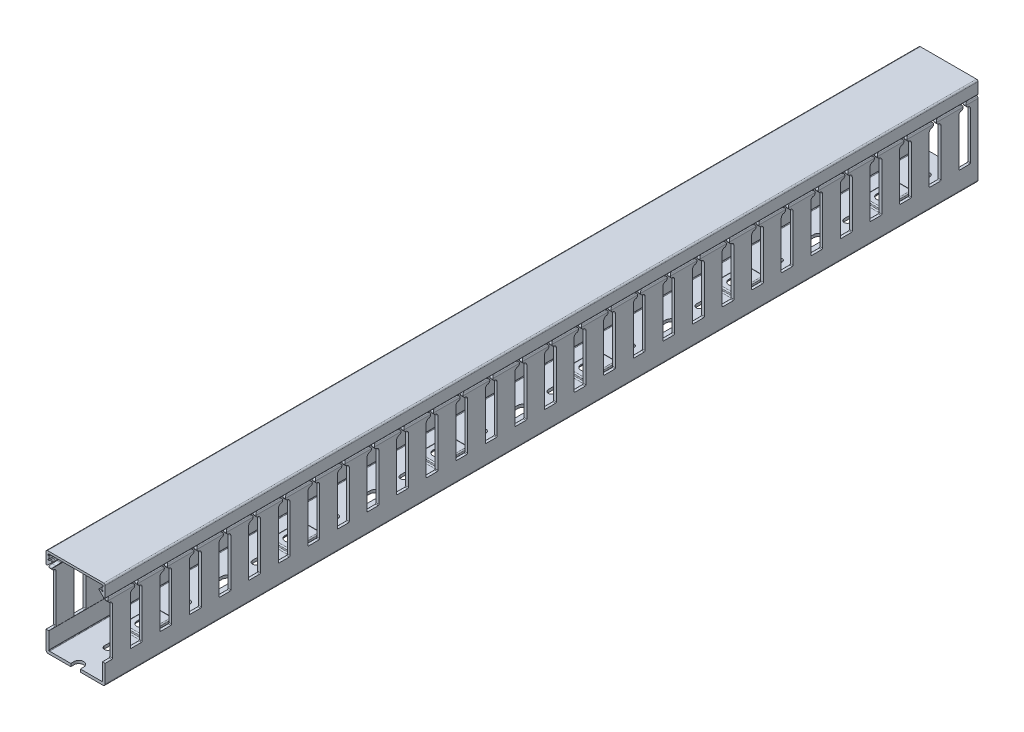
from build123d import *

# Parameters (mm, degrees)
BOSS_EXTRUDE1_START    = -295
BOSS_EXTRUDE1_DEPTH    = 590
BOSS_EXTRUDE2_START    = -295
BOSS_EXTRUDE2_DEPTH    = 590
BOSS_EXTRUDE3_START    = -30.05
SKETCH5_W              = 14
SKETCH5_H              = 21.4142
BOSS_EXTRUDE3_DEPTH    = 4.4
CUT_EXTRUDE1_START     = -30.05
SKETCH6_W              = 12.536
SKETCH6_H              = 19.9502
CUT_EXTRUDE1_DEPTH     = 3.6678
FILLET1_R              = 0.732
LPATTERN1_COUNT        = 6
LPATTERN1_PITCH        = 100
FILLET1_OF_LPATTERN1_R = 0.732
CUT_EXTRUDE2_START     = -31.0500001
CUT_EXTRUDE2_DEPTH     = 62.1000001
LPATTERN2_COUNT        = 7
LPATTERN2_PITCH        = 100
CUT_EXTRUDE3_DEPTH     = 21
LPATTERN4_COUNT        = 32
LPATTERN4_PITCH        = 20


with BuildPart() as part:
    # Sketch3 → Boss-Extrude1 (new body)
    with BuildSketch(Plane.XY.offset(BOSS_EXTRUDE1_START)):
        with BuildLine():
            Line((15.952670815, 24.4903301), (19.152670815, 21.40012602))
            ThreePointArc((19.152670815, 21.40012602), (19.695365564, 21.299543494), (20, 21.759795921))
            Line((20, 21.759795921), (20, 29.05))
            ThreePointArc((20, 29.05), (19.707106781, 29.757106781), (19, 30.05))
            Line((19, 30.05), (-19, 30.05))
            ThreePointArc((-19, 30.05), (-19.707106781, 29.757106781), (-20, 29.05))
            Line((-20, 29.05), (-20, 21.759795921))
            ThreePointArc((-20, 21.759795921), (-19.695365564, 21.299543494), (-19.152670815, 21.40012602))
            Line((-19.152670815, 21.40012602), (-15.952670815, 24.4903301))
            ThreePointArc((-15.952670815, 24.4903301), (-15.836408073, 25.037303297), (-16.3, 25.35))
            Line((-16.3, 25.35), (-17.01977827, 25.35))
            ThreePointArc((-17.01977827, 25.35), (-17.207081567, 25.313591927), (-17.367107455, 25.2096699))
            Line((-17.367107455, 25.2096699), (-17.822136652, 24.770253313))
            ThreePointArc((-17.822136652, 24.770253313), (-18.256292451, 24.689787291), (-18.5, 25.057989233))
            Line((-18.5, 25.057989233), (-18.5, 25.25))
            ThreePointArc((-18.5, 25.25), (-18.470710678, 25.320710678), (-18.4, 25.35))
            Line((-18.4, 25.35), (-18.2, 25.35))
            ThreePointArc((-18.2, 25.35), (-18.058578644, 25.408578644), (-18, 25.55))
            Line((-18, 25.55), (-18, 27.25))
            ThreePointArc((-18, 27.25), (-18.058578644, 27.391421356), (-18.2, 27.45))
            Line((-18.2, 27.45), (-18.4, 27.45))
            ThreePointArc((-18.4, 27.45), (-18.470710678, 27.479289322), (-18.5, 27.55))
            Line((-18.5, 27.55), (-18.5, 28.35))
            ThreePointArc((-18.5, 28.35), (-18.441421356, 28.491421356), (-18.3, 28.55))
            Line((-18.3, 28.55), (18.3, 28.55))
            ThreePointArc((18.3, 28.55), (18.441421356, 28.491421356), (18.5, 28.35))
            Line((18.5, 28.35), (18.5, 27.55))
            ThreePointArc((18.5, 27.55), (18.470710678, 27.479289322), (18.4, 27.45))
            Line((18.4, 27.45), (18.2, 27.45))
            ThreePointArc((18.2, 27.45), (18.058578644, 27.391421356), (18, 27.25))
            Line((18, 27.25), (18, 25.55))
            ThreePointArc((18, 25.55), (18.058578644, 25.408578644), (18.2, 25.35))
            Line((18.2, 25.35), (18.4, 25.35))
            ThreePointArc((18.4, 25.35), (18.470710678, 25.320710678), (18.5, 25.25))
            Line((18.5, 25.25), (18.5, 25.057989233))
            ThreePointArc((18.5, 25.057989233), (18.256292451, 24.689787291), (17.822136652, 24.770253313))
            Line((17.822136652, 24.770253313), (17.367107455, 25.2096699))
            ThreePointArc((17.367107455, 25.2096699), (17.207081567, 25.313591927), (17.01977827, 25.35))
            Line((17.01977827, 25.35), (16.3, 25.35))
            ThreePointArc((16.3, 25.35), (15.836408073, 25.037303297), (15.952670815, 24.4903301))
        make_face()
    extrude(amount=BOSS_EXTRUDE1_DEPTH)


with BuildPart() as body_2:
    # Sketch4 → Boss-Extrude2 (new body)
    with BuildSketch(Plane.XY.offset(BOSS_EXTRUDE2_START)):
        with BuildLine():
            Line((18.2, -27.85), (17.97299254, -27.982981329))
            ThreePointArc((17.97299254, -27.982981329), (17.80433959, -28.106339054), (17.6, -28.15))
            Line((17.6, -28.15), (-17.6, -28.15))
            ThreePointArc((-17.6, -28.15), (-17.80433959, -28.106339054), (-17.97299254, -27.982981329))
            Line((-17.97299254, -27.982981329), (-18.2, -27.85))
            Line((-18.2, -27.85), (-18.08202108, -27.782874671))
            ThreePointArc((-18.08202108, -27.782874671), (-18.095484884, -27.717042747), (-18.1, -27.65))
            Line((-18.1, -27.65), (-18.1, -16.507735027))
            Line((-18.1, -16.507735027), (-18.2, -16.45))
            Line((-18.2, -16.45), (-18.1, -16.392264973))
            Line((-18.1, -16.392264973), (-18.1, 18.84159723))
            ThreePointArc((-18.1, 18.84159723), (-18.066790213, 19.020781205), (-17.971572413, 19.176162533))
            Line((-17.971572413, 19.176162533), (-14.86028457, 22.631597749))
            ThreePointArc((-14.86028457, 22.631597749), (-14.267656312, 22.954958117), (-13.762339314, 23.402646525))
            ThreePointArc((-13.762339314, 23.402646525), (-13.419555232, 23.962019308), (-13.3, 24.607081617))
            Line((-13.3, 24.607081617), (-13.3, 25.85))
            ThreePointArc((-13.3, 25.85), (-13.827207794, 27.122792206), (-15.1, 27.65))
            Line((-15.1, 27.65), (-16.088349161, 27.65))
            ThreePointArc((-16.088349161, 27.65), (-16.887746934, 27.462750198), (-17.520825735, 26.939959112))
            ThreePointArc((-17.520825735, 26.939959112), (-17.828732042, 26.814376215), (-18.12760996, 26.668604651))
            ThreePointArc((-18.12760996, 26.668604651), (-18.451503706, 25.793986483), (-17.618826668, 25.373851922))
            Line((-17.618826668, 25.373851922), (-16.381173332, 25.705480134))
            ThreePointArc((-16.381173332, 25.705480134), (-15.603151885, 25.395081051), (-15.679798622, 24.560940631))
            Line((-15.679798622, 24.560940631), (-19.614717238, 20.190770771))
            ThreePointArc((-19.614717238, 20.190770771), (-19.90037064, 19.724626786), (-20, 19.187074862))
            Line((-20, 19.187074862), (-20, -28.55))
            ThreePointArc((-20, -28.55), (-19.560660172, -29.610660172), (-18.5, -30.05))
            Line((-18.5, -30.05), (18.5, -30.05))
            ThreePointArc((18.5, -30.05), (19.560660172, -29.610660172), (20, -28.55))
            Line((20, -28.55), (20, 19.187074862))
            ThreePointArc((20, 19.187074862), (19.90037064, 19.724626786), (19.614717238, 20.190770771))
            Line((19.614717238, 20.190770771), (15.679798622, 24.560940631))
            ThreePointArc((15.679798622, 24.560940631), (15.603151885, 25.395081051), (16.381173332, 25.705480134))
            Line((16.381173332, 25.705480134), (17.618826668, 25.373851922))
            ThreePointArc((17.618826668, 25.373851922), (18.451503706, 25.793986483), (18.12760996, 26.668604651))
            ThreePointArc((18.12760996, 26.668604651), (17.828732042, 26.814376215), (17.520825735, 26.939959112))
            ThreePointArc((17.520825735, 26.939959112), (16.887746934, 27.462750198), (16.088349161, 27.65))
            Line((16.088349161, 27.65), (15.1, 27.65))
            ThreePointArc((15.1, 27.65), (13.827207794, 27.122792206), (13.3, 25.85))
            Line((13.3, 25.85), (13.3, 24.607081617))
            ThreePointArc((13.3, 24.607081617), (13.419555232, 23.962019308), (13.762339314, 23.402646525))
            ThreePointArc((13.762339314, 23.402646525), (14.267656312, 22.954958117), (14.86028457, 22.631597749))
            Line((14.86028457, 22.631597749), (17.971572413, 19.176162533))
            ThreePointArc((17.971572413, 19.176162533), (18.066790213, 19.020781205), (18.1, 18.84159723))
            Line((18.1, 18.84159723), (18.1, -16.392264973))
            Line((18.1, -16.392264973), (18.2, -16.45))
            Line((18.2, -16.45), (18.1, -16.507735027))
            Line((18.1, -16.507735027), (18.1, -27.65))
            ThreePointArc((18.1, -27.65), (18.095484884, -27.717042747), (18.08202108, -27.782874671))
            Line((18.08202108, -27.782874671), (18.2, -27.85))
        make_face()
    extrude(amount=BOSS_EXTRUDE2_DEPTH)

    # Sketch5 → Boss-Extrude3 (add)
    with BuildSketch(Plane(origin=(0, 0, 0), x_dir=(1, 0, 0), z_dir=(0, 1, 0)).offset(BOSS_EXTRUDE3_START)):
        with Locations((0, -246.5)):
            Rectangle(SKETCH5_W, SKETCH5_H)
    boss_extrude3 = extrude(amount=BOSS_EXTRUDE3_DEPTH)

    # Sketch6 → Cut-Extrude1 (cut)
    with BuildSketch(Plane(origin=(0, 0, 0), x_dir=(1, 0, 0), z_dir=(0, 1, 0)).offset(CUT_EXTRUDE1_START)):
        with Locations((0, -246.5)):
            Rectangle(SKETCH6_W, SKETCH6_H)
    cut_extrude1 = extrude(amount=CUT_EXTRUDE1_DEPTH, mode=Mode.SUBTRACT)

    # Fillet1
    fillet1_edges = [body_2.edges().sort_by_distance(p)[0] for p in [
        (7, -26.9, 257.2071),
        (7, -28.15, 246.5),
        (7, -26.9, 235.7929),
        (0, -28.15, 235.7929),
        (-7, -26.9, 235.7929),
        (-7, -28.15, 246.5),
        (-7, -26.9, 257.2071),
        (0, -28.15, 257.2071),
        (7, -25.65, 246.5),
        (0, -25.65, 235.7929),
        (-7, -25.65, 246.5),
        (0, -25.65, 257.2071),
        (0, -30.05, 256.4751),
        (-6.268, -28.2161, 256.4751),
        (6.268, -30.05, 246.5),
        (6.268, -28.2161, 256.4751),
        (0, -30.05, 236.5249),
        (6.268, -28.2161, 236.5249),
        (-6.268, -30.05, 246.5),
        (-6.268, -28.2161, 236.5249),
        (0, -26.3822, 256.4751),
        (6.268, -26.3822, 246.5),
        (0, -26.3822, 236.5249),
        (-6.268, -26.3822, 246.5),
    ]]
    fillet(fillet1_edges, radius=FILLET1_R)

    # LPattern1: Boss-Extrude3, Cut-Extrude1 ×6
    with Locations(*[(0, 0, -i * LPATTERN1_PITCH) for i in range(1, LPATTERN1_COUNT)]):
        add(boss_extrude3)
        add(cut_extrude1, mode=Mode.SUBTRACT)

    # Fillet1 of LPattern1
    fillet1_of_lpattern1_edges = [body_2.edges().sort_by_distance(p)[0] for p in [
        (7, -26.9, 157.2071),
        (7, -28.15, 146.5),
        (7, -26.9, 135.7929),
        (0, -28.15, 135.7929),
        (-7, -26.9, 135.7929),
        (-7, -28.15, 146.5),
        (-7, -26.9, 157.2071),
        (0, -28.15, 157.2071),
        (7, -25.65, 146.5),
        (0, -25.65, 135.7929),
        (-7, -25.65, 146.5),
        (0, -25.65, 157.2071),
        (0, -30.05, 156.4751),
        (-6.268, -28.2161, 156.4751),
        (6.268, -30.05, 146.5),
        (6.268, -28.2161, 156.4751),
        (0, -30.05, 136.5249),
        (6.268, -28.2161, 136.5249),
        (-6.268, -30.05, 146.5),
        (-6.268, -28.2161, 136.5249),
        (0, -26.3822, 156.4751),
        (6.268, -26.3822, 146.5),
        (0, -26.3822, 136.5249),
        (-6.268, -26.3822, 146.5),
        (7, -26.9, 57.2071),
        (7, -28.15, 46.5),
        (7, -26.9, 35.7929),
        (0, -28.15, 35.7929),
        (-7, -26.9, 35.7929),
        (-7, -28.15, 46.5),
        (-7, -26.9, 57.2071),
        (0, -28.15, 57.2071),
        (7, -25.65, 46.5),
        (0, -25.65, 35.7929),
        (-7, -25.65, 46.5),
        (0, -25.65, 57.2071),
        (0, -30.05, 56.4751),
        (-6.268, -28.2161, 56.4751),
        (6.268, -30.05, 46.5),
        (6.268, -28.2161, 56.4751),
        (0, -30.05, 36.5249),
        (6.268, -28.2161, 36.5249),
        (-6.268, -30.05, 46.5),
        (-6.268, -28.2161, 36.5249),
        (0, -26.3822, 56.4751),
        (6.268, -26.3822, 46.5),
        (0, -26.3822, 36.5249),
        (-6.268, -26.3822, 46.5),
        (7, -26.9, -42.7929),
        (7, -28.15, -53.5),
        (7, -26.9, -64.2071),
        (0, -28.15, -64.2071),
        (-7, -26.9, -64.2071),
        (-7, -28.15, -53.5),
        (-7, -26.9, -42.7929),
        (0, -28.15, -42.7929),
        (7, -25.65, -53.5),
        (0, -25.65, -64.2071),
        (-7, -25.65, -53.5),
        (0, -25.65, -42.7929),
        (0, -30.05, -43.5249),
        (-6.268, -28.2161, -43.5249),
        (6.268, -30.05, -53.5),
        (6.268, -28.2161, -43.5249),
        (0, -30.05, -63.4751),
        (6.268, -28.2161, -63.4751),
        (-6.268, -30.05, -53.5),
        (-6.268, -28.2161, -63.4751),
        (0, -26.3822, -43.5249),
        (6.268, -26.3822, -53.5),
        (0, -26.3822, -63.4751),
        (-6.268, -26.3822, -53.5),
        (7, -26.9, -142.7929),
        (7, -28.15, -153.5),
        (7, -26.9, -164.2071),
        (0, -28.15, -164.2071),
        (-7, -26.9, -164.2071),
        (-7, -28.15, -153.5),
        (-7, -26.9, -142.7929),
        (0, -28.15, -142.7929),
        (7, -25.65, -153.5),
        (0, -25.65, -164.2071),
        (-7, -25.65, -153.5),
        (0, -25.65, -142.7929),
        (0, -30.05, -143.5249),
        (-6.268, -28.2161, -143.5249),
        (6.268, -30.05, -153.5),
        (6.268, -28.2161, -143.5249),
        (0, -30.05, -163.4751),
        (6.268, -28.2161, -163.4751),
        (-6.268, -30.05, -153.5),
        (-6.268, -28.2161, -163.4751),
        (0, -26.3822, -143.5249),
        (6.268, -26.3822, -153.5),
        (0, -26.3822, -163.4751),
        (-6.268, -26.3822, -153.5),
        (7, -26.9, -242.7929),
        (7, -28.15, -253.5),
        (7, -26.9, -264.2071),
        (0, -28.15, -264.2071),
        (-7, -26.9, -264.2071),
        (-7, -28.15, -253.5),
        (-7, -26.9, -242.7929),
        (0, -28.15, -242.7929),
        (7, -25.65, -253.5),
        (0, -25.65, -264.2071),
        (-7, -25.65, -253.5),
        (0, -25.65, -242.7929),
        (0, -30.05, -243.5249),
        (-6.268, -28.2161, -243.5249),
        (6.268, -30.05, -253.5),
        (6.268, -28.2161, -243.5249),
        (0, -30.05, -263.4751),
        (6.268, -28.2161, -263.4751),
        (-6.268, -30.05, -253.5),
        (-6.268, -28.2161, -263.4751),
        (0, -26.3822, -243.5249),
        (6.268, -26.3822, -253.5),
        (0, -26.3822, -263.4751),
        (-6.268, -26.3822, -253.5),
    ]]
    fillet(fillet1_of_lpattern1_edges, radius=FILLET1_OF_LPATTERN1_R)

    # Sketch7 → Cut-Extrude2 (cut)
    with BuildSketch(Plane(origin=(0, 0, 0), x_dir=(1, 0, 0), z_dir=(0, 1, 0)).offset(CUT_EXTRUDE2_START)):
        with BuildLine():
            Line((-2.25, -223.25), (-2.25, -219.75))
            ThreePointArc((-2.25, -219.75), (0, -217.5), (2.25, -219.75))
            Line((2.25, -219.75), (2.25, -223.25))
            ThreePointArc((2.25, -223.25), (0, -225.5), (-2.25, -223.25))
        make_face()
        with BuildLine():
            Line((-3.25, -250.25), (-3.25, -242.75))
            ThreePointArc((-3.25, -242.75), (0, -239.5), (3.25, -242.75))
            Line((3.25, -242.75), (3.25, -250.25))
            ThreePointArc((3.25, -250.25), (0, -253.5), (-3.25, -250.25))
        make_face()
        with BuildLine():
            Line((-2.25, -273.25), (-2.25, -269.75))
            ThreePointArc((-2.25, -269.75), (0, -267.5), (2.25, -269.75))
            Line((2.25, -269.75), (2.25, -273.25))
            ThreePointArc((2.25, -273.25), (0, -275.5), (-2.25, -273.25))
        make_face()
        with BuildLine():
            Line((-3.25, -300.25), (-3.25, -292.75))
            ThreePointArc((-3.25, -292.75), (0, -289.5), (3.25, -292.75))
            Line((3.25, -292.75), (3.25, -300.25))
            ThreePointArc((3.25, -300.25), (0, -303.5), (-3.25, -300.25))
        make_face()
    cut_extrude2 = extrude(amount=CUT_EXTRUDE2_DEPTH, mode=Mode.SUBTRACT)

    # LPattern2: Cut-Extrude2 ×7
    with Locations(*[(0, 0, -i * LPATTERN2_PITCH) for i in range(1, LPATTERN2_COUNT)]):
        add(cut_extrude2, mode=Mode.SUBTRACT)

    # Sketch8 → Cut-Extrude3 (cut, symmetric)
    with BuildSketch(Plane(origin=(0, 0, 0), x_dir=(0, 0, -1), z_dir=(1, 0, 0))):
        with BuildLine():
            Line((-298.00000029, 15.685898343), (-298.00000029, -15.95))
            ThreePointArc((-298.00000029, -15.95), (-297.853553681, -16.303553391), (-297.50000029, -16.45))
            Line((-297.50000029, -16.45), (-290.50000029, -16.45))
            ThreePointArc((-290.50000029, -16.45), (-290.146446899, -16.303553391), (-290.00000029, -15.95))
            Line((-290.00000029, -15.95), (-290.00000029, 15.685898343))
            ThreePointArc((-290.00000029, 15.685898343), (-290.488142453, 16.995205748), (-291.71428617, 17.665385004))
            ThreePointArc((-291.71428617, 17.665385004), (-293.00000058, 19.15), (-291.71428617, 20.634614996))
            ThreePointArc((-291.71428617, 20.634614996), (-290.488142453, 21.304794252), (-290.00000029, 22.614101657))
            Line((-290.00000029, 22.614101657), (-290.00000029, 51.285898343))
            ThreePointArc((-290.00000029, 51.285898343), (-290.488142453, 52.595205748), (-291.71428617, 53.265385004))
            ThreePointArc((-291.71428617, 53.265385004), (-293.00000058, 54.75), (-291.71428617, 56.234614996))
            ThreePointArc((-291.71428617, 56.234614996), (-290.488142453, 56.904794252), (-290.00000029, 58.214101657))
            Line((-290.00000029, 58.214101657), (-290.00000029, 90.35))
            Line((-290.00000029, 90.35), (-298.00000029, 90.35))
            Line((-298.00000029, 90.35), (-298.00000029, 58.214101657))
            ThreePointArc((-298.00000029, 58.214101657), (-297.511858127, 56.904794252), (-296.28571441, 56.234614996))
            ThreePointArc((-296.28571441, 56.234614996), (-295, 54.75), (-296.28571441, 53.265385004))
            ThreePointArc((-296.28571441, 53.265385004), (-297.511858127, 52.595205748), (-298.00000029, 51.285898343))
            Line((-298.00000029, 51.285898343), (-298.00000029, 22.614101657))
            ThreePointArc((-298.00000029, 22.614101657), (-297.511858127, 21.304794252), (-296.28571441, 20.634614996))
            ThreePointArc((-296.28571441, 20.634614996), (-295, 19.15), (-296.28571441, 17.665385004))
            ThreePointArc((-296.28571441, 17.665385004), (-297.511858127, 16.995205748), (-298.00000029, 15.685898343))
        make_face()
    cut_extrude3 = extrude(amount=CUT_EXTRUDE3_DEPTH, both=True, mode=Mode.SUBTRACT)

    # LPattern4: Cut-Extrude3 ×32
    with Locations(*[(0, 0, -i * LPATTERN4_PITCH) for i in range(1, LPATTERN4_COUNT)]):
        add(cut_extrude3, mode=Mode.SUBTRACT)


solid = Compound([part.part, body_2.part])
